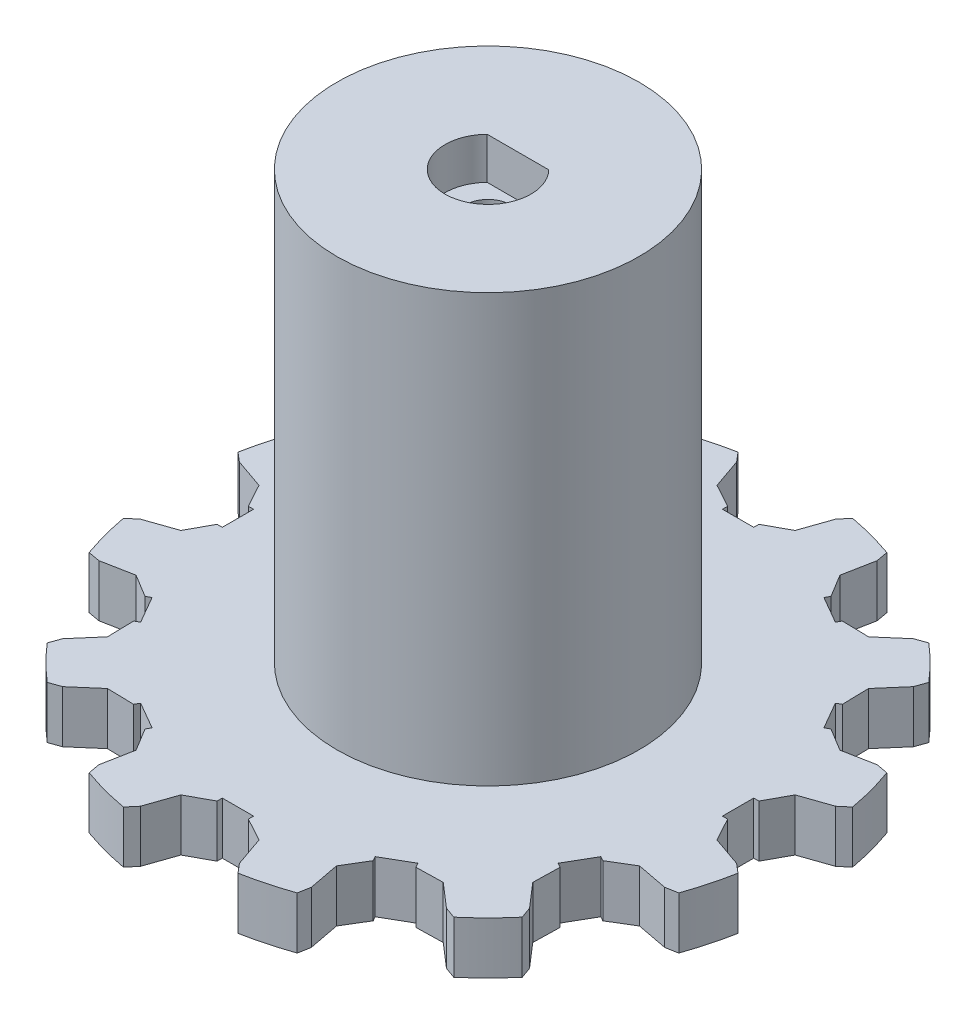
from build123d import *

# Parameters (mm, degrees)
BOSS_EXTRUDE1_DEPTH     = 5
SKETCH2_R               = 14.5
BOSS_EXTRUDE3_DEPTH     = 41
CUT_EXTRUDE2_DEPTH      = 4
SKETCH10_R              = 2.125
CUT_EXTRUDE4_DEPTH      = 1
CUT_EXTRUDE4_DEPTH_BACK = 47
SKETCH11_R              = 3.625
CUT_EXTRUDE5_DEPTH      = 10


with BuildPart() as part:
    # Sketch1 → Boss-Extrude1 (new body)
    with BuildSketch(Plane(origin=(0, 0, 0), x_dir=(1, 0, 0), z_dir=(0, 1, 0))):
        with BuildLine():
            Line((-1.5, 24.494818027), (-3.75, 25.728146066))
            Line((-3.75, 25.728146066), (-4.75, 28.608346684))
            Line((-4.75, 28.608346684), (-5.5, 29.491524206))
            ThreePointArc((-5.5, 29.491524206), (-6.518225952, 29.283318296), (-7.528629065, 29.039968051))
            ThreePointArc((-7.528629065, 29.039968051), (-7.764571353, 28.977774789), (-8, 28.91366459))
            ThreePointArc((-8, 28.91366459), (-8.996709886, 28.619210528), (-9.982622382, 28.290409159))
            Line((-9.982622382, 28.290409159), (-10.190552674, 27.150554989))
            Line((-10.190552674, 27.150554989), (-9.616477769, 24.156228086))
            Line((-9.616477769, 24.156228086), (-10.948370908, 21.963134673))
            Line((-10.948370908, 21.963134673), (-10.700961894, 21.534609691))
            Line((-10.700961894, 21.534609691), (-13.299038106, 20.034609691))
            Line((-13.299038106, 20.034609691), (-13.546447119, 20.463134673))
            Line((-13.546447119, 20.463134673), (-16.111668297, 20.406228086))
            Line((-16.111668297, 20.406228086), (-18.41779401, 22.400554989))
            Line((-18.41779401, 22.400554989), (-19.508901824, 22.790409159))
            ThreePointArc((-19.508901824, 22.790409159), (-20.28660841, 22.100984575), (-21.039968051, 21.385035525))
            ThreePointArc((-21.039968051, 21.385035525), (-21.213203436, 21.213203436), (-21.385035525, 21.039968051))
            ThreePointArc((-21.385035525, 21.039968051), (-22.100984575, 20.28660841), (-22.790409159, 19.508901824))
            Line((-22.790409159, 19.508901824), (-22.400554989, 18.41779401))
            Line((-22.400554989, 18.41779401), (-20.406228086, 16.111668297))
            Line((-20.406228086, 16.111668297), (-20.463134673, 13.546447119))
            Line((-20.463134673, 13.546447119), (-20.034609691, 13.299038106))
            Line((-20.034609691, 13.299038106), (-21.534609691, 10.700961894))
            Line((-21.534609691, 10.700961894), (-21.963134673, 10.948370908))
            Line((-21.963134673, 10.948370908), (-24.156228086, 9.616477769))
            Line((-24.156228086, 9.616477769), (-27.150554989, 10.190552674))
            Line((-27.150554989, 10.190552674), (-28.290409159, 9.982622382))
            ThreePointArc((-28.290409159, 9.982622382), (-28.619210528, 8.996709886), (-28.91366459, 8))
            ThreePointArc((-28.91366459, 8), (-28.977774789, 7.764571353), (-29.039968051, 7.528629065))
            ThreePointArc((-29.039968051, 7.528629065), (-29.283318296, 6.518225952), (-29.491524206, 5.5))
            Line((-29.491524206, 5.5), (-28.608346684, 4.75))
            Line((-28.608346684, 4.75), (-25.728146066, 3.75))
            Line((-25.728146066, 3.75), (-24.494818027, 1.5))
            Line((-24.494818027, 1.5), (-24, 1.5))
            Line((-24, 1.5), (-24, -1.5))
            Line((-24, -1.5), (-24.494818027, -1.5))
            Line((-24.494818027, -1.5), (-25.728146066, -3.75))
            Line((-25.728146066, -3.75), (-28.608346684, -4.75))
            Line((-28.608346684, -4.75), (-29.491524206, -5.5))
            ThreePointArc((-29.491524206, -5.5), (-29.283318296, -6.518225952), (-29.039968051, -7.528629065))
            ThreePointArc((-29.039968051, -7.528629065), (-28.977774789, -7.764571353), (-28.91366459, -8))
            ThreePointArc((-28.91366459, -8), (-28.619210528, -8.996709886), (-28.290409159, -9.982622382))
            Line((-28.290409159, -9.982622382), (-27.150554989, -10.190552674))
            Line((-27.150554989, -10.190552674), (-24.156228086, -9.616477769))
            Line((-24.156228086, -9.616477769), (-21.963134673, -10.948370908))
            Line((-21.963134673, -10.948370908), (-21.534609691, -10.700961894))
            Line((-21.534609691, -10.700961894), (-20.034609691, -13.299038106))
            Line((-20.034609691, -13.299038106), (-20.463134673, -13.546447119))
            Line((-20.463134673, -13.546447119), (-20.406228086, -16.111668297))
            Line((-20.406228086, -16.111668297), (-22.400554989, -18.41779401))
            Line((-22.400554989, -18.41779401), (-22.790409159, -19.508901824))
            ThreePointArc((-22.790409159, -19.508901824), (-22.100984575, -20.28660841), (-21.385035525, -21.039968051))
            ThreePointArc((-21.385035525, -21.039968051), (-21.213203436, -21.213203436), (-21.039968051, -21.385035525))
            ThreePointArc((-21.039968051, -21.385035525), (-20.28660841, -22.100984575), (-19.508901824, -22.790409159))
            Line((-19.508901824, -22.790409159), (-18.41779401, -22.400554989))
            Line((-18.41779401, -22.400554989), (-16.111668297, -20.406228086))
            Line((-16.111668297, -20.406228086), (-13.546447119, -20.463134673))
            Line((-13.546447119, -20.463134673), (-13.299038106, -20.034609691))
            Line((-13.299038106, -20.034609691), (-10.700961894, -21.534609691))
            Line((-10.700961894, -21.534609691), (-10.948370908, -21.963134673))
            Line((-10.948370908, -21.963134673), (-9.616477769, -24.156228086))
            Line((-9.616477769, -24.156228086), (-10.190552674, -27.150554989))
            Line((-10.190552674, -27.150554989), (-9.982622382, -28.290409159))
            ThreePointArc((-9.982622382, -28.290409159), (-8.996709886, -28.619210528), (-8, -28.91366459))
            ThreePointArc((-8, -28.91366459), (-7.764571353, -28.977774789), (-7.528629065, -29.039968051))
            ThreePointArc((-7.528629065, -29.039968051), (-6.518225952, -29.283318296), (-5.5, -29.491524206))
            Line((-5.5, -29.491524206), (-4.75, -28.608346684))
            Line((-4.75, -28.608346684), (-3.75, -25.728146066))
            Line((-3.75, -25.728146066), (-1.5, -24.494818027))
            Line((-1.5, -24.494818027), (-1.5, -24))
            Line((-1.5, -24), (1.5, -24))
            Line((1.5, -24), (1.5, -24.494818027))
            Line((1.5, -24.494818027), (3.75, -25.728146066))
            Line((3.75, -25.728146066), (4.75, -28.608346684))
            Line((4.75, -28.608346684), (5.5, -29.491524206))
            ThreePointArc((5.5, -29.491524206), (6.518225952, -29.283318296), (7.528629065, -29.039968051))
            ThreePointArc((7.528629065, -29.039968051), (7.764571353, -28.977774789), (8, -28.91366459))
            ThreePointArc((8, -28.91366459), (8.996709886, -28.619210528), (9.982622382, -28.290409159))
            Line((9.982622382, -28.290409159), (10.190552674, -27.150554989))
            Line((10.190552674, -27.150554989), (9.616477769, -24.156228086))
            Line((9.616477769, -24.156228086), (10.948370908, -21.963134673))
            Line((10.948370908, -21.963134673), (10.700961894, -21.534609691))
            Line((10.700961894, -21.534609691), (13.299038106, -20.034609691))
            Line((13.299038106, -20.034609691), (13.546447119, -20.463134673))
            Line((13.546447119, -20.463134673), (16.111668297, -20.406228086))
            Line((16.111668297, -20.406228086), (18.41779401, -22.400554989))
            Line((18.41779401, -22.400554989), (19.508901824, -22.790409159))
            ThreePointArc((19.508901824, -22.790409159), (20.28660841, -22.100984575), (21.039968051, -21.385035525))
            ThreePointArc((21.039968051, -21.385035525), (21.213203436, -21.213203436), (21.385035525, -21.039968051))
            ThreePointArc((21.385035525, -21.039968051), (22.100984575, -20.28660841), (22.790409159, -19.508901824))
            Line((22.790409159, -19.508901824), (22.400554989, -18.41779401))
            Line((22.400554989, -18.41779401), (20.406228086, -16.111668297))
            Line((20.406228086, -16.111668297), (20.463134673, -13.546447119))
            Line((20.463134673, -13.546447119), (20.034609691, -13.299038106))
            Line((20.034609691, -13.299038106), (21.534609691, -10.700961894))
            Line((21.534609691, -10.700961894), (21.963134673, -10.948370908))
            Line((21.963134673, -10.948370908), (24.156228086, -9.616477769))
            Line((24.156228086, -9.616477769), (27.150554989, -10.190552674))
            Line((27.150554989, -10.190552674), (28.290409159, -9.982622382))
            ThreePointArc((28.290409159, -9.982622382), (28.619210528, -8.996709886), (28.91366459, -8))
            ThreePointArc((28.91366459, -8), (28.977774789, -7.764571353), (29.039968051, -7.528629065))
            ThreePointArc((29.039968051, -7.528629065), (29.283318296, -6.518225952), (29.491524206, -5.5))
            Line((29.491524206, -5.5), (28.608346684, -4.75))
            Line((28.608346684, -4.75), (25.728146066, -3.75))
            Line((25.728146066, -3.75), (24.494818027, -1.5))
            Line((24.494818027, -1.5), (24, -1.5))
            Line((24, -1.5), (24, 1.5))
            Line((24, 1.5), (24.494818027, 1.5))
            Line((24.494818027, 1.5), (25.728146066, 3.75))
            Line((25.728146066, 3.75), (28.608346684, 4.75))
            Line((28.608346684, 4.75), (29.491524206, 5.5))
            ThreePointArc((29.491524206, 5.5), (29.283318296, 6.518225952), (29.039968051, 7.528629065))
            ThreePointArc((29.039968051, 7.528629065), (28.977774789, 7.764571353), (28.91366459, 8))
            ThreePointArc((28.91366459, 8), (28.619210528, 8.996709886), (28.290409159, 9.982622382))
            Line((28.290409159, 9.982622382), (27.150554989, 10.190552674))
            Line((27.150554989, 10.190552674), (24.156228086, 9.616477769))
            Line((24.156228086, 9.616477769), (21.963134673, 10.948370908))
            Line((21.963134673, 10.948370908), (21.534609691, 10.700961894))
            Line((21.534609691, 10.700961894), (20.034609691, 13.299038106))
            Line((20.034609691, 13.299038106), (20.463134673, 13.546447119))
            Line((20.463134673, 13.546447119), (20.406228086, 16.111668297))
            Line((20.406228086, 16.111668297), (22.400554989, 18.41779401))
            Line((22.400554989, 18.41779401), (22.790409159, 19.508901824))
            ThreePointArc((22.790409159, 19.508901824), (22.100984575, 20.28660841), (21.385035525, 21.039968051))
            ThreePointArc((21.385035525, 21.039968051), (21.213203436, 21.213203436), (21.039968051, 21.385035525))
            ThreePointArc((21.039968051, 21.385035525), (20.28660841, 22.100984575), (19.508901824, 22.790409159))
            Line((19.508901824, 22.790409159), (18.41779401, 22.400554989))
            Line((18.41779401, 22.400554989), (16.111668297, 20.406228086))
            Line((16.111668297, 20.406228086), (13.546447119, 20.463134673))
            Line((13.546447119, 20.463134673), (13.299038106, 20.034609691))
            Line((13.299038106, 20.034609691), (10.700961894, 21.534609691))
            Line((10.700961894, 21.534609691), (10.948370908, 21.963134673))
            Line((10.948370908, 21.963134673), (9.616477769, 24.156228086))
            Line((9.616477769, 24.156228086), (10.190552674, 27.150554989))
            Line((10.190552674, 27.150554989), (9.982622382, 28.290409159))
            ThreePointArc((9.982622382, 28.290409159), (8.996709886, 28.619210528), (8, 28.91366459))
            ThreePointArc((8, 28.91366459), (7.764571353, 28.977774789), (7.528629065, 29.039968051))
            ThreePointArc((7.528629065, 29.039968051), (6.518225952, 29.283318296), (5.5, 29.491524206))
            Line((5.5, 29.491524206), (4.75, 28.608346684))
            Line((4.75, 28.608346684), (3.75, 25.728146066))
            Line((3.75, 25.728146066), (1.5, 24.494818027))
            Line((1.5, 24.494818027), (1.5, 24))
            Line((1.5, 24), (-1.5, 24))
            Line((-1.5, 24), (-1.5, 24.494818027))
        make_face()
    extrude(amount=BOSS_EXTRUDE1_DEPTH)

    # Sketch2 → Boss-Extrude3 (add)
    with BuildSketch(Plane(origin=(0, 5, 0), x_dir=(1, 0, 0), z_dir=(0, 1, 0))):
        Circle(SKETCH2_R)
    extrude(amount=BOSS_EXTRUDE3_DEPTH)

    # Sketch4 → Cut-Extrude2 (cut)
    with BuildSketch(Plane(origin=(0, 46, 0), x_dir=(1, 0, 0), z_dir=(0, 1, 0))):
        with BuildLine():
            ThreePointArc((4.125, 0), (3.82214204, 1.551404275), (2.958039892, 2.875))
            Line((2.958039892, 2.875), (-2.958039892, 2.875))
            ThreePointArc((-2.958039892, 2.875), (-1.551404275, -3.82214204), (4.125, 0))
        make_face()
    extrude(amount=-CUT_EXTRUDE2_DEPTH, mode=Mode.SUBTRACT)

    # Sketch10 → Cut-Extrude4 (cut, two sides)
    with BuildSketch(Plane.XZ) as cut_extrude4_sk:
        Circle(SKETCH10_R)
    extrude(amount=CUT_EXTRUDE4_DEPTH, mode=Mode.SUBTRACT)
    extrude(cut_extrude4_sk.sketch, amount=-CUT_EXTRUDE4_DEPTH_BACK, mode=Mode.SUBTRACT)

    # Sketch11 → Cut-Extrude5 (cut)
    with BuildSketch(Plane(origin=(0, 0, 0), x_dir=(-1, 0, 0), z_dir=(0, -1, 0))):
        Circle(SKETCH11_R)
    extrude(amount=-CUT_EXTRUDE5_DEPTH, mode=Mode.SUBTRACT)


solid = part.part
